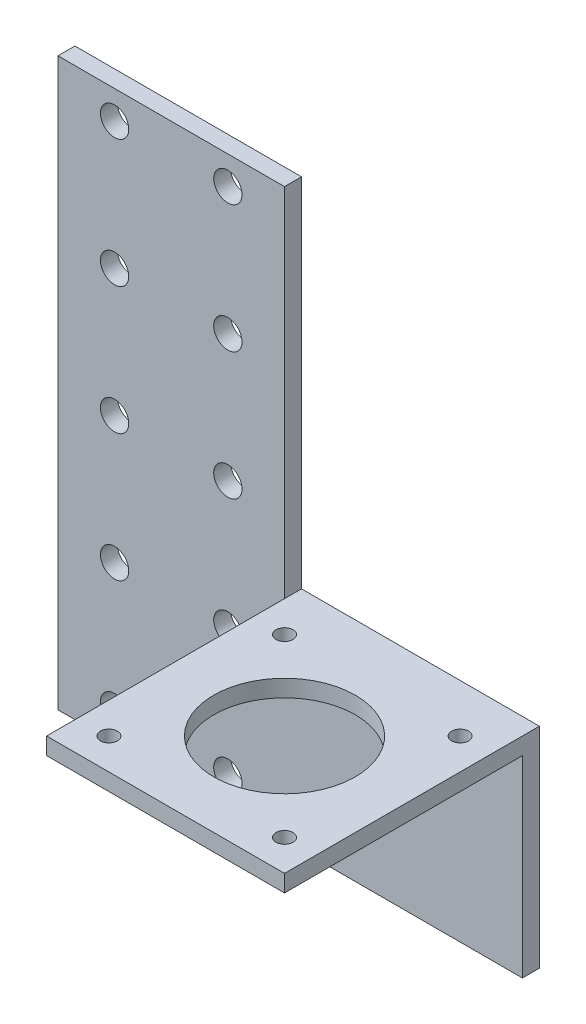
from build123d import *

# Parameters (mm, degrees)
SKETCH1_R           = 2.5
BOSS_EXTRUDE1_DEPTH = 3
SKETCH2_W           = 42
SKETCH2_H           = 45
BOSS_EXTRUDE2_DEPTH = 3
SKETCH3_R           = 12.5
SKETCH3_R_2         = 1.5
CUT_EXTRUDE1_DEPTH  = 13


with BuildPart() as part:
    # Sketch1 → Boss-Extrude1 (new body)
    with BuildSketch(Plane.XY):
        Polygon((40, 0), (0, 0), (0, -100), (82, -100), (82, -66), (40, -66), align=None)
        with Locations((30, -5)):
            Circle(SKETCH1_R, mode=Mode.SUBTRACT)
        with Locations((10, -5)):
            Circle(SKETCH1_R, mode=Mode.SUBTRACT)
        with Locations((10, -27.5)):
            Circle(SKETCH1_R, mode=Mode.SUBTRACT)
        with Locations((10, -50)):
            Circle(SKETCH1_R, mode=Mode.SUBTRACT)
        with Locations((10, -72.5)):
            Circle(SKETCH1_R, mode=Mode.SUBTRACT)
        with Locations((10, -95)):
            Circle(SKETCH1_R, mode=Mode.SUBTRACT)
        with Locations((30, -27.5)):
            Circle(SKETCH1_R, mode=Mode.SUBTRACT)
        with Locations((30, -50)):
            Circle(SKETCH1_R, mode=Mode.SUBTRACT)
        with Locations((30, -72.5)):
            Circle(SKETCH1_R, mode=Mode.SUBTRACT)
        with Locations((30, -95)):
            Circle(SKETCH1_R, mode=Mode.SUBTRACT)
    extrude(amount=BOSS_EXTRUDE1_DEPTH)

    # Sketch2 → Boss-Extrude2 (add)
    with BuildSketch(Plane(origin=(0, -66, 0), x_dir=(1, 0, 0), z_dir=(0, 1, 0))):
        with Locations((61, -22.5)):
            Rectangle(SKETCH2_W, SKETCH2_H)
    extrude(amount=BOSS_EXTRUDE2_DEPTH)

    # Sketch3 → Cut-Extrude1 (cut)
    with BuildSketch(Plane.XZ.offset(66)):
        with Locations((61, 24)):
            Circle(SKETCH3_R)
        with Locations((45.5, 39.5)):
            Circle(SKETCH3_R_2)
        with Locations((45.5, 8.5)):
            Circle(SKETCH3_R_2)
        with Locations((76.5, 8.5)):
            Circle(SKETCH3_R_2)
        with Locations((76.5, 39.5)):
            Circle(SKETCH3_R_2)
    extrude(amount=-CUT_EXTRUDE1_DEPTH, mode=Mode.SUBTRACT)


solid = part.part
